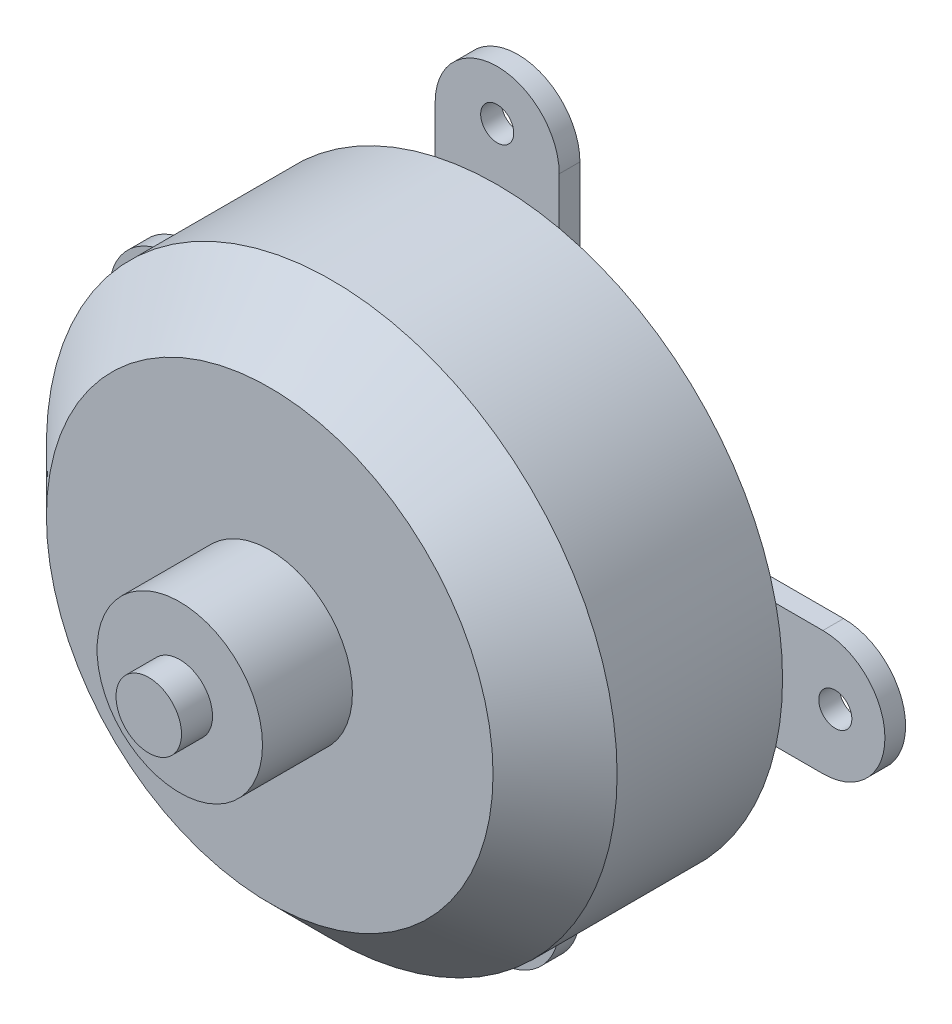
from build123d import *

# Parameters (mm, degrees)
BOSS_EXTRU_2_DEPTH                            = 1
ESQUISSE4_R                                   = 3
BOSS_EXTRU_5_DEPTH                            = 1
TROU_POUR_TARAUDAGE_POUR_TROU_TARAUD_M2_D     = 1.6
TROU_POUR_TARAUDAGE_POUR_TROU_TARAUD_M2_DEPTH = 10
TROU_POUR_TARAUDAGE_POUR_TROU_TARAUD_M2_TIP   = 0.480688495
ESQUISSE8_R                                   = 13.8
BOSS_EXTRU_6_DEPTH                            = 11
CHANFREIN1_SIZE                               = 3
ESQUISSE13_R                                  = 4
BOSS_EXTRU_7_DEPTH                            = 4.35
ESQUISSE14_R                                  = 1.583459573
BOSS_EXTRU_8_DEPTH                            = 1.5


with BuildPart() as part:
    # Esquisse3 → Boss.-Extru.2 (new body)
    with BuildSketch(Plane.XY):
        Polygon((-44.638743765, 23.961876808), (-44.638743765, 11.211876808), (-57.388743765, 11.211876808), (-57.388743765, 5.211876808), (-44.638743765, 5.211876808), (-44.638743765, -7.538123192), (-38.638743765, -7.538123192), (-38.638743765, 5.211876808), (-25.888743765, 5.211876808), (-25.888743765, 11.211876808), (-38.638743765, 11.211876808), (-38.638743765, 23.961876808), align=None)
    extrude(amount=BOSS_EXTRU_2_DEPTH)

    # Esquisse4 → Boss.-Extru.5 (add)
    with BuildSketch(Plane.XY.offset(1)):
        with Locations((-41.638743765, 23.961876808)):
            Circle(ESQUISSE4_R)
        with Locations((-25.888743765, 8.211876808)):
            Circle(ESQUISSE4_R)
        with Locations((-41.638743765, -7.538123192)):
            Circle(ESQUISSE4_R)
        with Locations((-57.388743765, 8.211876808)):
            Circle(ESQUISSE4_R)
    extrude(amount=-BOSS_EXTRU_5_DEPTH)

    # Trou pour taraudage pour trou taraudé M2x0.41
    with Locations(Plane.XY.offset(1)):
        with Locations((-41.638743765, 24.561876808), (-25.288743765, 8.211876808), (-41.638743765, -8.138123192), (-57.988743765, 8.211876808)):
            Hole(TROU_POUR_TARAUDAGE_POUR_TROU_TARAUD_M2_D / 2, depth=TROU_POUR_TARAUDAGE_POUR_TROU_TARAUD_M2_DEPTH)
            with Locations((0, 0, -(TROU_POUR_TARAUDAGE_POUR_TROU_TARAUD_M2_DEPTH + TROU_POUR_TARAUDAGE_POUR_TROU_TARAUD_M2_TIP / 2))):  # 118° drill point
                Cone(0, TROU_POUR_TARAUDAGE_POUR_TROU_TARAUD_M2_D / 2, TROU_POUR_TARAUDAGE_POUR_TROU_TARAUD_M2_TIP, mode=Mode.SUBTRACT)

    # Esquisse8 → Boss.-Extru.6 (add)
    with BuildSketch(Plane.XY.offset(1)):
        with Locations((-41.638743765, 8.211876808)):
            Circle(ESQUISSE8_R)
    extrude(amount=BOSS_EXTRU_6_DEPTH)

    # Chanfrein1
    chanfrein1_edges = [part.edges().sort_by_distance(p)[0] for p in [
        (-55.438743765, 8.211876808, 12),
    ]]
    chamfer(chanfrein1_edges, length=CHANFREIN1_SIZE)

    # Esquisse13 → Boss.-Extru.7 (add)
    with BuildSketch(Plane.XY.offset(12)):
        with Locations((-41.638743765, 8.211876808)):
            Circle(ESQUISSE13_R)
    extrude(amount=BOSS_EXTRU_7_DEPTH)

    # Esquisse14 → Boss.-Extru.8 (add)
    with BuildSketch(Plane.XY.offset(16.35)):
        with Locations((-41.638743765, 8.211876808)):
            Circle(ESQUISSE14_R)
    extrude(amount=BOSS_EXTRU_8_DEPTH)


solid = part.part
